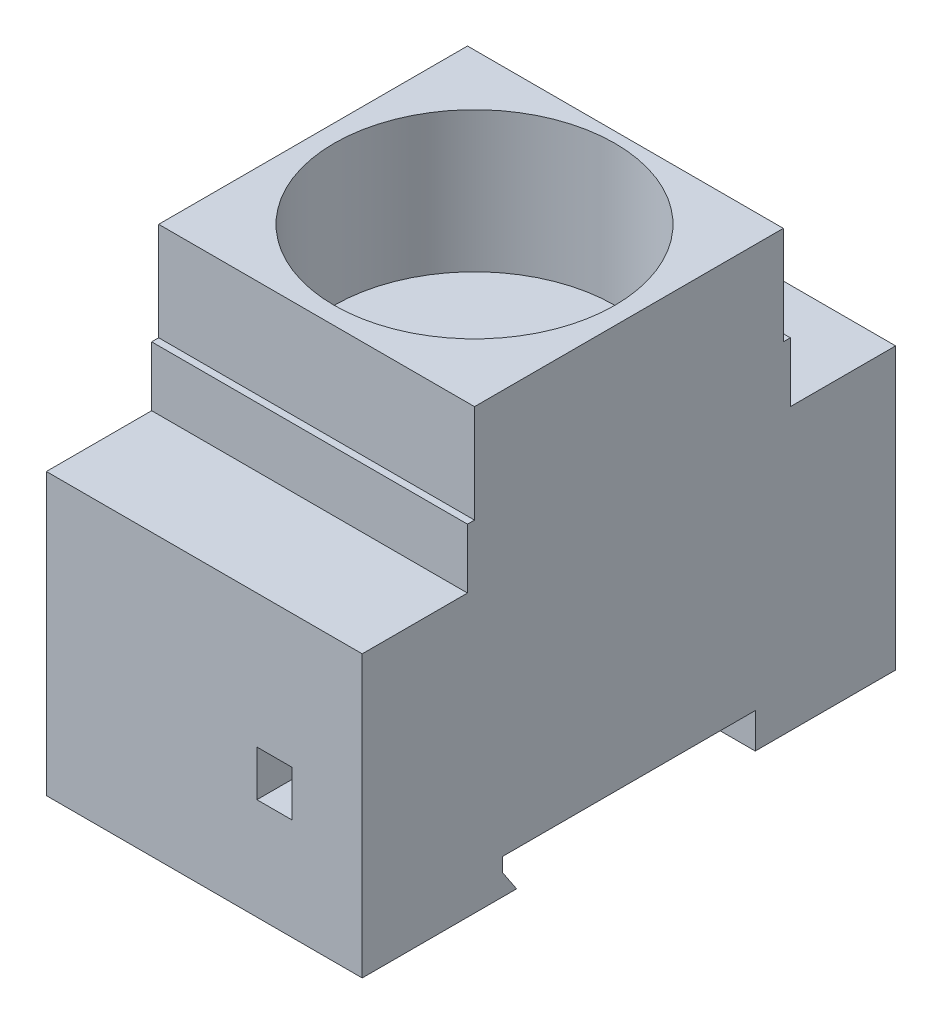
from build123d import *

# Parameters (mm, degrees)
EXTRUDE_1_DEPTH     = 45
SKETCH_2_R          = 20
CUT_EXTRUDE_1_DEPTH = 20
SKETCH_3_W          = 5
SKETCH_3_H          = 6.5
CUT_EXTRUDE_2_DEPTH = 20
SKETCH_4_W          = 5
SKETCH_4_H          = 6.5
CUT_EXTRUDE_3_DEPTH = 20


with BuildPart() as part:
    # Эскиз1 → Бобышка-Вытянуть1 (new body)
    with BuildSketch(Plane(origin=(0, 0, 0), x_dir=(0, 0, -1), z_dir=(1, 0, 0))):
        Polygon((0, 0), (0, 40), (15, 40), (15, 48.5), (16, 48.5), (16, 62.5), (60, 62.5), (60, 48.5), (61, 48.5), (61, 40), (76, 40), (76, 0), (56, 0), (56, 5), (20, 5), (20, 3), (22, 0), align=None)
    extrude(amount=EXTRUDE_1_DEPTH)

    # Эскиз2 → Вырез-Вытянуть1 (cut)
    with BuildSketch(Plane(origin=(0, 62.5, 0), x_dir=(1, 0, 0), z_dir=(0, 1, 0))):
        with Locations((22.5, 38.5)):
            Circle(SKETCH_2_R)
    extrude(amount=-CUT_EXTRUDE_1_DEPTH, mode=Mode.SUBTRACT)

    # Эскиз3 → Вырез-Вытянуть2 (cut)
    with BuildSketch(Plane.XY):
        with Locations((32.5, 17.75)):
            Rectangle(SKETCH_3_W, SKETCH_3_H)
    extrude(amount=-CUT_EXTRUDE_2_DEPTH, mode=Mode.SUBTRACT)

    # Эскиз4 → Вырез-Вытянуть3 (cut)
    with BuildSketch(Plane(origin=(0, 0, -76), x_dir=(-1, 0, 0), z_dir=(0, 0, -1))):
        with Locations((-32.5, 17.75)):
            Rectangle(SKETCH_4_W, SKETCH_4_H)
        with Locations((-12.5, 17.75)):
            Rectangle(SKETCH_4_W, SKETCH_4_H)
    extrude(amount=-CUT_EXTRUDE_3_DEPTH, mode=Mode.SUBTRACT)


solid = part.part
